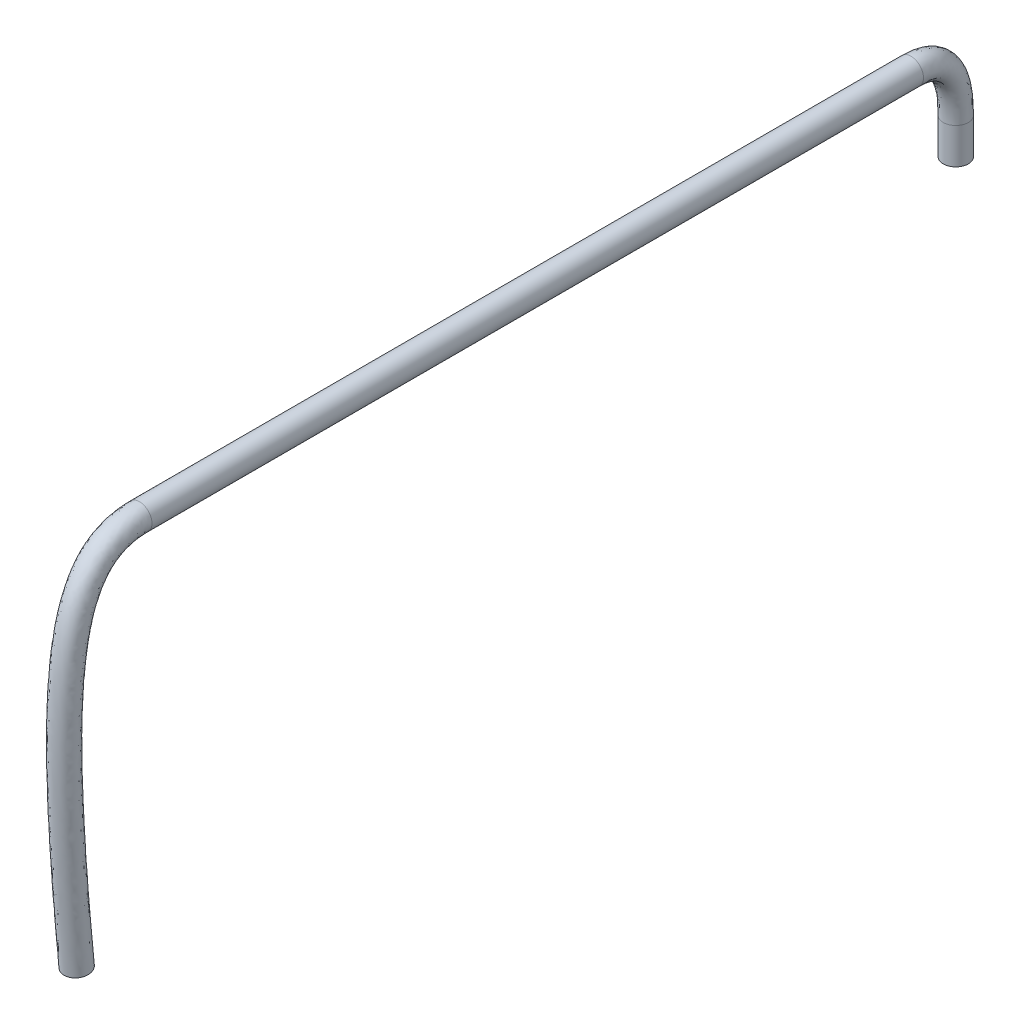
from build123d import *

# Parameters (mm, degrees)
SKETCH2_R = 0.7


with BuildPart() as part:
    # Sweep1: sweep along a path in Sketch1
    with BuildLine() as sweep1_path:  # in the path sketch's own coordinates; laid on its plane below (add() does not lay a ready-made edge on the line's plane)
        Line((0, 0), (0, 2))
        add(Edge.make_bspline(
            [(0, 2), (0, 3.674235304), (-0.430345499, 5.4), (-2.5, 5.4)],
            knots=[0, 0, 0, 0, 1, 1, 1, 1], degree=3))
        Line((-2.5, 5.4), (-45.5, 5.4))
        add(Edge.make_bspline(
            [(-45.5, 5.4), (-49.957704936, 5.4), (-50.373533333, -0.252618042), (-49, -14.6)],
            knots=[0, 0, 0, 0, 1, 1, 1, 1], degree=3))
    # Sketch2 → Sweep1 (sweep)
    with BuildSketch(Plane(origin=(0, 0, 0), x_dir=(1, 0, 0), z_dir=(0, 1, 0))):
        Circle(SKETCH2_R)
    sweep(path=Plane(origin=(0, 0, 0), x_dir=(0, 0, -1), z_dir=(1, 0, 0)) * sweep1_path.line)


solid = part.part
